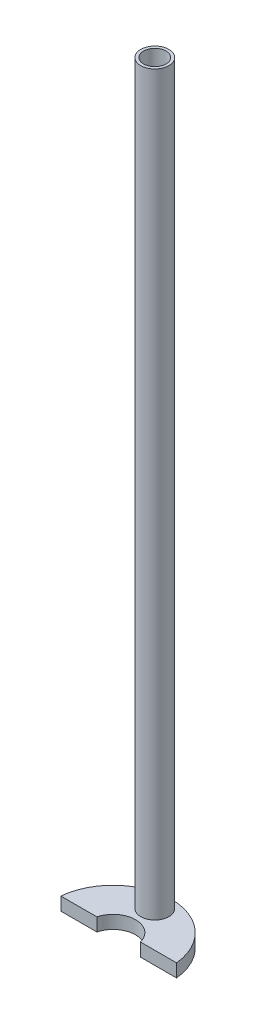
from build123d import *

# Parameters (mm, degrees)
BOSS_EXTRUDE1_DEPTH = 3.5
SKETCH2_5_R         = 3.75
BOSS_EXTRUDE2_DEPTH = 200
SKETCH3_R           = 3
CUT_EXTRUDE1_DEPTH  = 202.192072408


with BuildPart() as part:
    # Sketch2 → Boss-Extrude1 (new body)
    with BuildSketch(Plane(origin=(0, 0, 0), x_dir=(1, 0, 0), z_dir=(0, 1, 0))):
        with BuildLine():
            ThreePointArc((15.427248621, 1.5), (0, 15.5), (-15.427248621, 1.5))
            Line((-15.427248621, 1.5), (-5.809475019, 1.5))
            ThreePointArc((-5.809475019, 1.5), (0, 6), (5.809475019, 1.5))
            Line((5.809475019, 1.5), (15.427248621, 1.5))
        make_face()
    extrude(amount=BOSS_EXTRUDE1_DEPTH)

    # Sketch2_5 → Boss-Extrude2 (add)
    with BuildSketch(Plane(origin=(0, 0, 0), x_dir=(1, 0, 0), z_dir=(0, 1, 0))):
        with Locations((0, 11.125)):
            Circle(SKETCH2_5_R)
    extrude(amount=BOSS_EXTRUDE2_DEPTH)

    # Sketch3 → Cut-Extrude1 (cut, through all)
    with BuildSketch(Plane(origin=(0, 200, 0), x_dir=(1, 0, 0), z_dir=(0, 1, 0))):
        with Locations((0, 11.125)):
            Circle(SKETCH3_R)
    extrude(amount=-CUT_EXTRUDE1_DEPTH, mode=Mode.SUBTRACT)


solid = part.part
